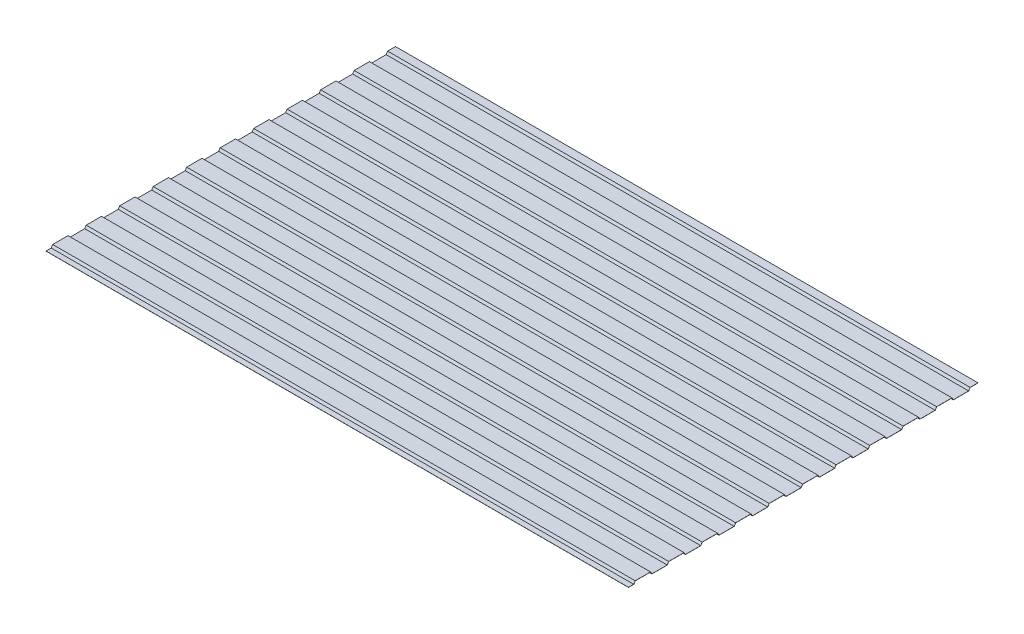
from build123d import *

# Parameters (mm, degrees)
EXTRUDE_1_DEPTH = 2000


with BuildPart() as part:
    # Эскиз1 → Вытянуть-Тонкостенный1 (new body)
    with BuildSketch(Plane(origin=(0, 0, 0), x_dir=(0, 0, -1), z_dir=(1, 0, 0))):
        Polygon((-18, -0.2), (0.110849528, -0.2), (5.110849528, 7.8), (57.389150472, 7.8), (62.389150472, -0.2), (115.110849528, -0.2), (120.110849528, 7.8), (172.389150472, 7.8), (177.389150472, -0.2), (230.110849528, -0.2), (235.110849528, 7.8), (287.389150472, 7.8), (292.389150472, -0.2), (345.110849528, -0.2), (350.110849528, 7.8), (402.389150472, 7.8), (407.389150472, -0.2), (460.110849528, -0.2), (465.110849528, 7.8), (517.389150472, 7.8), (522.389150472, -0.2), (575.110849528, -0.2), (580.110849528, 7.8), (632.389150472, 7.8), (637.389150472, -0.2), (690.110849528, -0.2), (695.110849528, 7.8), (747.389150472, 7.8), (752.389150472, -0.2), (805.110849528, -0.2), (810.110849528, 7.8), (862.389150472, 7.8), (867.389150472, -0.2), (920.110849528, -0.2), (925.110849528, 7.8), (977.389150472, 7.8), (982.389150472, -0.2), (1035.110849528, -0.2), (1040.110849528, 7.8), (1092.389150472, 7.8), (1097.389150472, -0.2), (1150.110849528, -0.2), (1155.110849528, 7.8), (1182, 7.8), (1182, 8.2), (1154.889150472, 8.2), (1149.889150472, 0.2), (1097.610849528, 0.2), (1092.610849528, 8.2), (1039.889150472, 8.2), (1034.889150472, 0.2), (982.610849528, 0.2), (977.610849528, 8.2), (924.889150472, 8.2), (919.889150472, 0.2), (867.610849528, 0.2), (862.610849528, 8.2), (809.889150472, 8.2), (804.889150472, 0.2), (752.610849528, 0.2), (747.610849528, 8.2), (694.889150472, 8.2), (689.889150472, 0.2), (637.610849528, 0.2), (632.610849528, 8.2), (579.889150472, 8.2), (574.889150472, 0.2), (522.610849528, 0.2), (517.610849528, 8.2), (464.889150472, 8.2), (459.889150472, 0.2), (407.610849528, 0.2), (402.610849528, 8.2), (349.889150472, 8.2), (344.889150472, 0.2), (292.610849528, 0.2), (287.610849528, 8.2), (234.889150472, 8.2), (229.889150472, 0.2), (177.610849528, 0.2), (172.610849528, 8.2), (119.889150472, 8.2), (114.889150472, 0.2), (62.610849528, 0.2), (57.610849528, 8.2), (4.889150472, 8.2), (-0.110849528, 0.2), (-18, 0.2), align=None)
    extrude(amount=EXTRUDE_1_DEPTH)


solid = part.part
